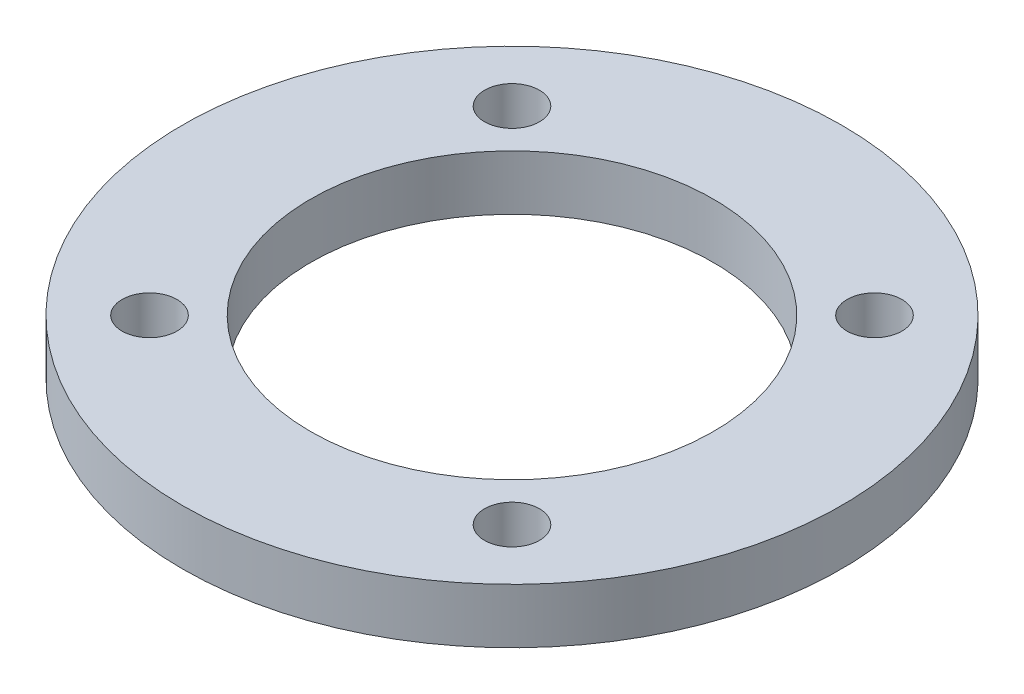
from build123d import *

# Parameters (mm, degrees)
SKETCH1_R           = 18
SKETCH1_R_2         = 11
SKETCH1_R_3         = 1.5
BOSS_EXTRUDE1_DEPTH = 3


with BuildPart() as part:
    # Sketch1 → Boss-Extrude1 (new body)
    with BuildSketch(Plane(origin=(0, 0, 0), x_dir=(1, 0, 0), z_dir=(0, 1, 0))):
        Circle(SKETCH1_R)
        Circle(SKETCH1_R_2, mode=Mode.SUBTRACT)
        with Locations((9.899494937, 9.899494937)):
            Circle(SKETCH1_R_3, mode=Mode.SUBTRACT)
        with Locations((9.899494937, -9.899494937)):
            Circle(SKETCH1_R_3, mode=Mode.SUBTRACT)
        with Locations((-9.899494937, -9.899494937)):
            Circle(SKETCH1_R_3, mode=Mode.SUBTRACT)
        with Locations((-9.899494937, 9.899494937)):
            Circle(SKETCH1_R_3, mode=Mode.SUBTRACT)
    extrude(amount=BOSS_EXTRUDE1_DEPTH)


solid = part.part
